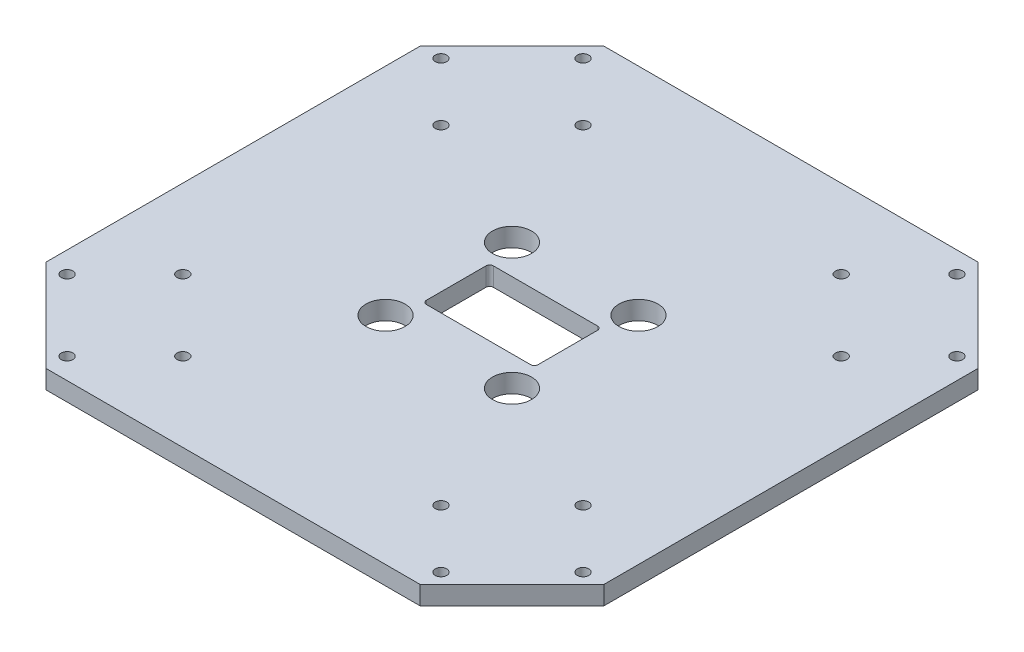
from build123d import *

# Parameters (mm, degrees)
SKETCH1_W           = 150
SKETCH1_H           = 150
BOSS_EXTRUDE1_DEPTH = 2.5
CUT_EXTRUDE1_DEPTH  = 5
SKETCH3_R           = 1.55
CUT_EXTRUDE2_DEPTH  = 5
SKETCH4_R           = 5.25
SKETCH4_W           = 30
SKETCH4_H           = 18
CUT_EXTRUDE3_DEPTH  = 5
FILLET1_R           = 1


with BuildPart() as part:
    # Sketch1 → Boss-Extrude1 (new body, symmetric)
    with BuildSketch(Plane(origin=(0, 0, 0), x_dir=(1, 0, 0), z_dir=(0, 1, 0))):
        Rectangle(SKETCH1_W, SKETCH1_H)
    extrude(amount=BOSS_EXTRUDE1_DEPTH, both=True)

    # Sketch2 → Cut-Extrude1 (cut)
    with BuildSketch(Plane(origin=(0, 2.5, 0), x_dir=(1, 0, 0), z_dir=(0, 1, 0))):
        Polygon((50.251262658, 75), (75, 75), (75, 50.251262658), align=None)
        Polygon((-75, 75), (-75, 50.251262658), (-50.251262658, 75), align=None)
        Polygon((-50.251262658, -75), (-75, -75), (-75, -50.251262658), align=None)
        Polygon((75, -75), (75, -50.251262658), (50.251262658, -75), align=None)
    extrude(amount=-CUT_EXTRUDE1_DEPTH, mode=Mode.SUBTRACT)

    # Sketch3 → Cut-Extrude2 (cut)
    with BuildSketch(Plane(origin=(0, 2.5, 0), x_dir=(1, 0, 0), z_dir=(0, 1, 0))):
        with Locations((69.343145751, 50.251262658)):
            Circle(SKETCH3_R)
        with Locations((53.786796564, 34.694913472)):
            Circle(SKETCH3_R)
        with Locations((34.694913472, 53.786796564)):
            Circle(SKETCH3_R)
        with Locations((50.251262658, 69.343145751)):
            Circle(SKETCH3_R)
        with Locations((-69.343145751, 50.251262658)):
            Circle(SKETCH3_R)
        with Locations((-53.786796564, 34.694913472)):
            Circle(SKETCH3_R)
        with Locations((-34.694913472, 53.786796564)):
            Circle(SKETCH3_R)
        with Locations((-50.251262658, 69.343145751)):
            Circle(SKETCH3_R)
        with Locations((-53.786796564, -34.694913472)):
            Circle(SKETCH3_R)
        with Locations((-69.343145751, -50.251262658)):
            Circle(SKETCH3_R)
        with Locations((-34.694913472, -53.786796564)):
            Circle(SKETCH3_R)
        with Locations((-50.251262658, -69.343145751)):
            Circle(SKETCH3_R)
        with Locations((69.343145751, -50.251262658)):
            Circle(SKETCH3_R)
        with Locations((53.786796564, -34.694913472)):
            Circle(SKETCH3_R)
        with Locations((34.694913472, -53.786796564)):
            Circle(SKETCH3_R)
        with Locations((50.251262658, -69.343145751)):
            Circle(SKETCH3_R)
    extrude(amount=-CUT_EXTRUDE2_DEPTH, mode=Mode.SUBTRACT)

    # Sketch4 → Cut-Extrude3 (cut)
    with BuildSketch(Plane(origin=(0, 2.5, 0), x_dir=(1, 0, 0), z_dir=(0, 1, 0))):
        with Locations((17, -17)):
            Circle(SKETCH4_R)
        with Locations((17, 17)):
            Circle(SKETCH4_R)
        with Locations((-17, -17)):
            Circle(SKETCH4_R)
        with Locations((-17, 17)):
            Circle(SKETCH4_R)
        Rectangle(SKETCH4_W, SKETCH4_H)
    extrude(amount=-CUT_EXTRUDE3_DEPTH, mode=Mode.SUBTRACT)

    # Fillet1
    fillet1_edges = [part.edges().sort_by_distance(p)[0] for p in [
        (-15, 0, 9),
        (-15, 0, -9),
        (15, 0, -9),
        (15, 0, 9),
    ]]
    fillet(fillet1_edges, radius=FILLET1_R)


solid = part.part
